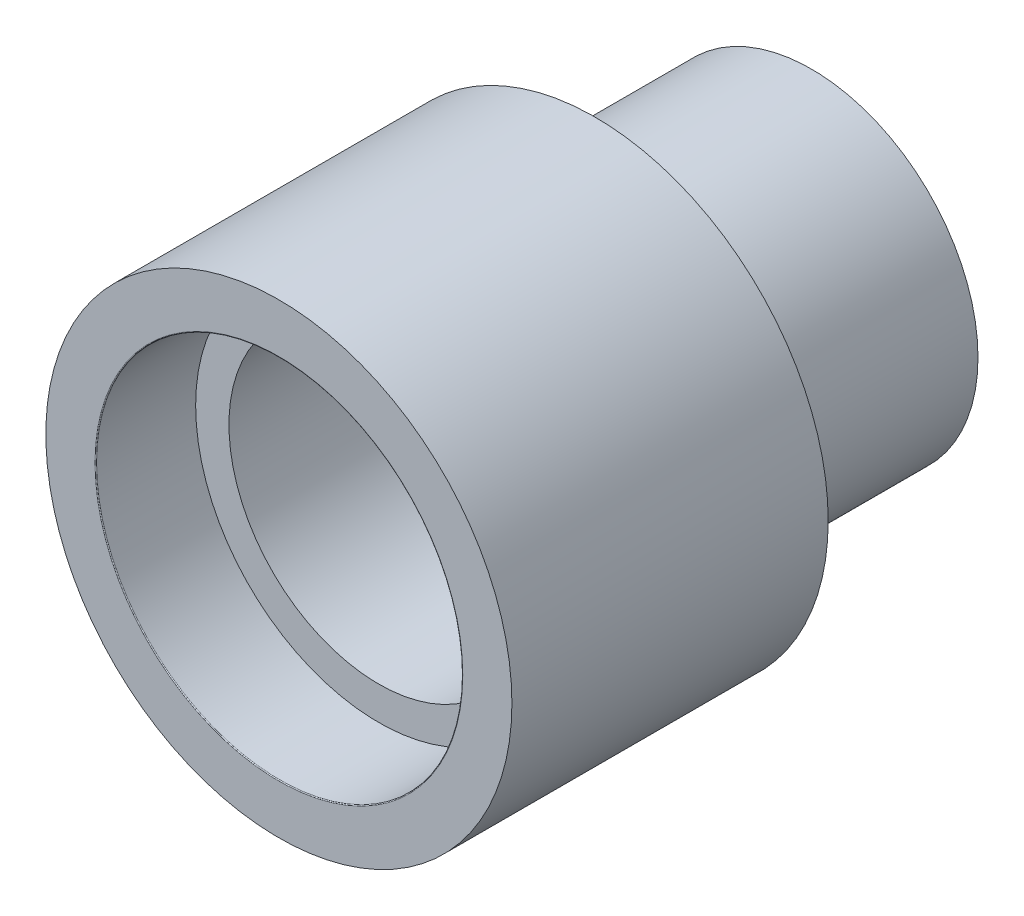
from build123d import *

# Parameters (mm, degrees)
SKETCH2_R           = 10
BOSS_EXTRUDE1_DEPTH = 13
SKETCH3_R           = 14
BOSS_EXTRUDE2_DEPTH = 19
SKETCH4_R           = 11
CUT_EXTRUDE1_DEPTH  = 6
SKETCH5_R           = 9
CUT_EXTRUDE2_DEPTH  = 10
SKETCH6_R           = 5
CUT_EXTRUDE3_DEPTH  = 33
FILLET1_R           = 0.05


with BuildPart() as part:
    # Sketch2 → Boss-Extrude1 (new body)
    with BuildSketch(Plane.XY):
        Circle(SKETCH2_R)
    extrude(amount=-BOSS_EXTRUDE1_DEPTH)

    # Sketch3 → Boss-Extrude2 (add)
    with BuildSketch(Plane.XY):
        Circle(SKETCH3_R)
    extrude(amount=BOSS_EXTRUDE2_DEPTH)

    # Sketch4 → Cut-Extrude1 (cut)
    with BuildSketch(Plane.XY.offset(19)):
        Circle(SKETCH4_R)
    extrude(amount=-CUT_EXTRUDE1_DEPTH, mode=Mode.SUBTRACT)

    # Sketch5 → Cut-Extrude2 (cut)
    with BuildSketch(Plane.XY.offset(13)):
        Circle(SKETCH5_R)
    extrude(amount=-CUT_EXTRUDE2_DEPTH, mode=Mode.SUBTRACT)

    # Sketch6 → Cut-Extrude3 (cut, through all)
    with BuildSketch(Plane(origin=(0, 0, -13), x_dir=(-1, 0, 0), z_dir=(0, 0, -1))):
        Circle(SKETCH6_R)
    extrude(amount=-CUT_EXTRUDE3_DEPTH, mode=Mode.SUBTRACT)

    # Fillet1
    fillet1_edges = [part.edges().sort_by_distance(p)[0] for p in [
        (-11, 0, 19),
    ]]
    fillet(fillet1_edges, radius=FILLET1_R)


solid = part.part
